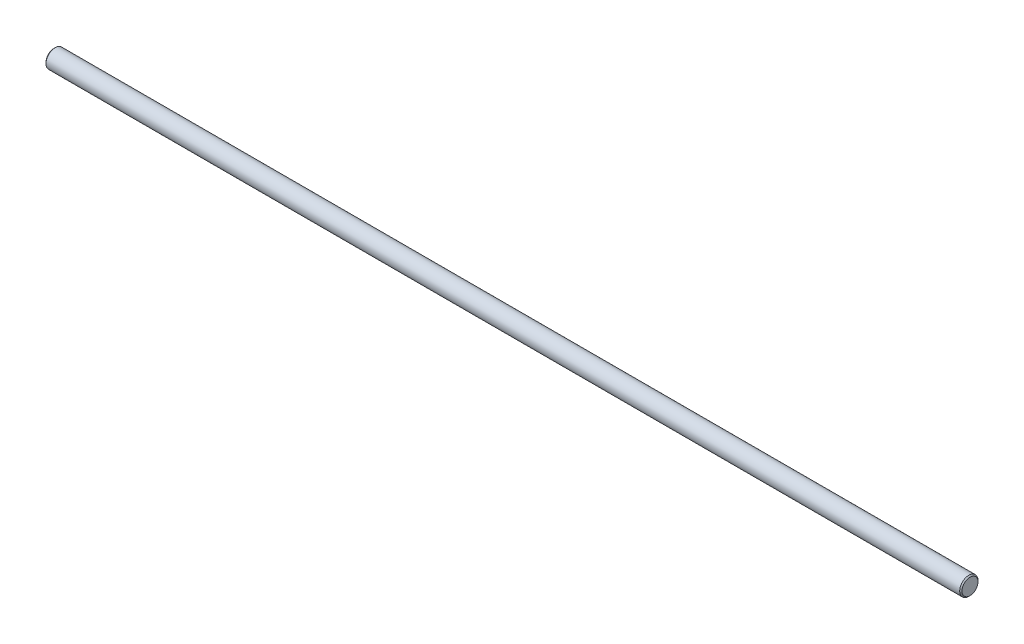
from build123d import *

# Parameters (mm, degrees)
SKETCH1_R           = 4
BOSS_EXTRUDE1_DEPTH = 400
CHAMFER1_SIZE       = 0.5


with BuildPart() as part:
    # Sketch1 → Boss-Extrude1 (new body)
    with BuildSketch(Plane(origin=(0, 0, 0), x_dir=(0, 0, -1), z_dir=(1, 0, 0))):
        Circle(SKETCH1_R)
    extrude(amount=BOSS_EXTRUDE1_DEPTH)

    # Chamfer1
    chamfer1_edges = [part.edges().sort_by_distance(p)[0] for p in [
        (0, 0, 4),
        (400, 0, 4),
    ]]
    chamfer(chamfer1_edges, length=CHAMFER1_SIZE)


solid = part.part
